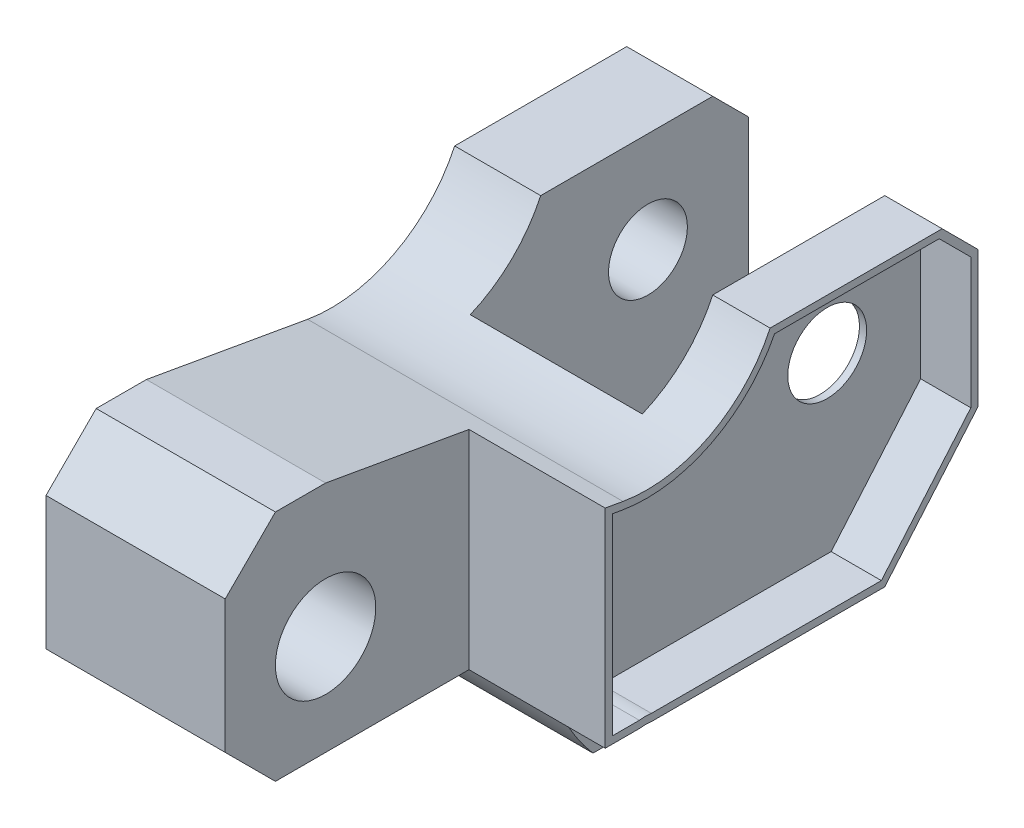
from build123d import *

# Parameters (mm, degrees)
SKETCH1_R               = 7
BOSS_EXTRUDE3_DEPTH     = 22
SKETCH8_R               = 5.5
CUT_EXTRUDE1_DEPTH      = 46
SKETCH10_W              = 34.059077951
SKETCH10_H              = 32.597107019
CUT_EXTRUDE2_DEPTH      = 19
SKETCH19_R              = 41
CUT_EXTRUDE5_DEPTH      = 14
CUT_EXTRUDE5_DEPTH_BACK = 10
SKETCH21_W              = 39.040087977
SKETCH21_H              = 19
CUT_EXTRUDE7_DEPTH      = 19
CUT_EXTRUDE8_DEPTH      = 7


with BuildPart() as part:
    # Sketch1 → Boss-Extrude3 (new body, symmetric)
    with BuildSketch(Plane(origin=(0, 0, 0), x_dir=(0, 0, -1), z_dir=(1, 0, 0))):
        with BuildLine():
            Line((0, 0), (24, 0))
            Line((24, 0), (29, -5))
            Line((29, -5), (29, -24))
            Line((29, -24), (0, -58))
            Line((0, -58), (-5.703019947, -58))
            ThreePointArc((-5.703019947, -58), (-7.775768892, -55.305839554), (-9.519025669, -52.387647562))
            ThreePointArc((-9.519025669, -52.387647562), (-11.35140658, -48.033040831), (-12.452414435, -43.438696342))
            ThreePointArc((-12.452414435, -43.438696342), (-14.440768413, -40.168970146), (-18.158792561, -39.262903161))
            Line((-18.158792561, -39.262903161), (-50, -39.262903161))
            Line((-50, -39.262903161), (-57, -32.262903161))
            Line((-57, -32.262903161), (-57, -13.71762228))
            Line((-57, -13.71762228), (-50, -6.71762228))
            Line((-50, -6.71762228), (-43, -6.71762228))
            Line((-43, -6.71762228), (-20.519163329, -10.681600334))
            ThreePointArc((-20.519163329, -10.681600334), (-8.446624302, -8.823458857), (0, 0))
        make_face()
        with Locations((-43, -25.262903161)):
            Circle(SKETCH1_R, mode=Mode.SUBTRACT)
    extrude(amount=BOSS_EXTRUDE3_DEPTH, both=True)

    # Sketch8 → Cut-Extrude1 (cut)
    with BuildSketch(Plane(origin=(22, 0, 0), x_dir=(0, 0, -1), z_dir=(1, 0, 0))):
        with Locations((14.962850045, -14)):
            Circle(SKETCH8_R)
    extrude(amount=-CUT_EXTRUDE1_DEPTH, mode=Mode.SUBTRACT)

    # Sketch10 → Cut-Extrude2 (cut)
    with BuildSketch(Plane(origin=(22, 0, 0), x_dir=(0, 0, -1), z_dir=(1, 0, 0))):
        with Locations((-40.029538976, -22.964349652)):
            Rectangle(SKETCH10_W, SKETCH10_H)
    extrude(amount=-CUT_EXTRUDE2_DEPTH, mode=Mode.SUBTRACT)

    # Sketch19 → Cut-Extrude5 (cut, two sides)
    with BuildSketch(Plane(origin=(0, 0, 0), x_dir=(0, 0, -1), z_dir=(1, 0, 0))) as cut_extrude5_sk:
        with Locations((29, 3.701873436)):
            Circle(SKETCH19_R)
    extrude(amount=CUT_EXTRUDE5_DEPTH, mode=Mode.SUBTRACT)
    extrude(cut_extrude5_sk.sketch, amount=-CUT_EXTRUDE5_DEPTH_BACK, mode=Mode.SUBTRACT)

    # Sketch21 → Cut-Extrude7 (cut)
    with BuildSketch(Plane(origin=(22, 0, 0), x_dir=(0, 0, -1), z_dir=(1, 0, 0))):
        with Locations((-3.479956011, -48.762903161)):
            Rectangle(SKETCH21_W, SKETCH21_H)
    extrude(amount=-CUT_EXTRUDE7_DEPTH, mode=Mode.SUBTRACT)

    # Sketch22 → Cut-Extrude8 (cut)
    with BuildSketch(Plane(origin=(22, 0, 0), x_dir=(0, 0, -1), z_dir=(1, 0, 0))):
        with BuildLine():
            Line((-16.554750267, -38.262903161), (15.520235364, -38.262903161))
            Line((15.520235364, -38.262903161), (28, -23.631454967))
            Line((28, -23.631454967), (28, -5.414213562))
            Line((28, -5.414213562), (23.585786438, -1))
            Line((23.585786438, -1), (0.625702461, -1))
            ThreePointArc((0.625702461, -1), (-8.270776569, -9.856396305), (-20.692811507, -11.666408087))
            Line((-20.692811507, -11.666408087), (-22, -11.435915487))
            Line((-22, -11.435915487), (-22, -38.262903161))
            Line((-22, -38.262903161), (-18.232249909, -38.262903161))
            ThreePointArc((-18.232249909, -38.262903161), (-17.393500088, -38.203988815), (-16.554750267, -38.262903161))
        make_face()
    extrude(amount=-CUT_EXTRUDE8_DEPTH, mode=Mode.SUBTRACT)


solid = part.part
